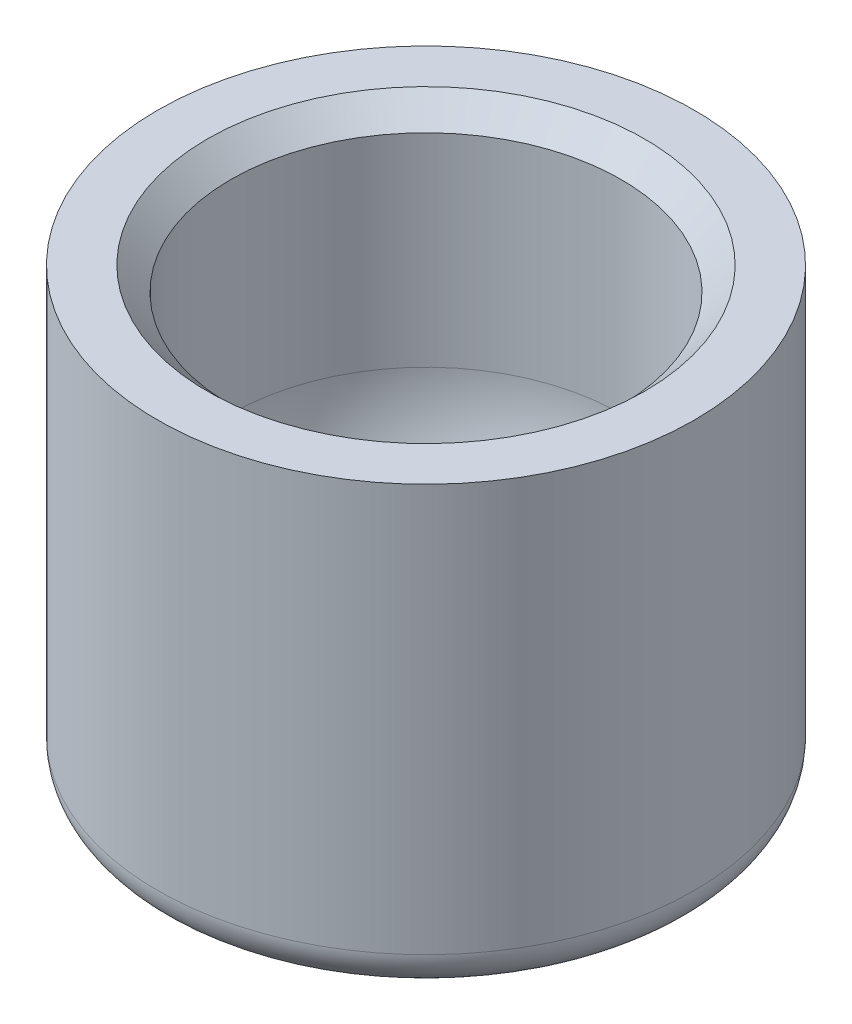
from build123d import *

# Parameters (mm, degrees)
CHAMFER1_SIZE = 0.762


with BuildPart() as part:
    # Sketch1 → Revolve1 (revolve)
    with BuildSketch(Plane.XY):
        with BuildLine():
            Line((6.35, 0), (8.73125, 0))
            Line((8.73125, 0), (8.73125, -13.25435082))
            ThreePointArc((8.73125, -13.25435082), (8.567676279, -13.87782567), (8.11909112, -14.340695636))
            Line((8.11909112, -14.340695636), (0.635, -18.872721569))
            ThreePointArc((0.635, -18.872721569), (0.329640957, -19.004848916), (0, -19.05))
            Line((0, -19.05), (0, -13.716))
            ThreePointArc((0, -13.716), (4.490128061, -11.856128061), (6.35, -7.366))
            Line((6.35, -7.366), (6.35, 0))
        make_face()
    revolve(axis=Axis((0, -13.716, 0), (0, -1, 0)))

    # Chamfer1
    chamfer1_edges = [part.edges().sort_by_distance(p)[0] for p in [
        (-6.35, 0, 0),
    ]]
    chamfer(chamfer1_edges, length=CHAMFER1_SIZE)


solid = part.part
